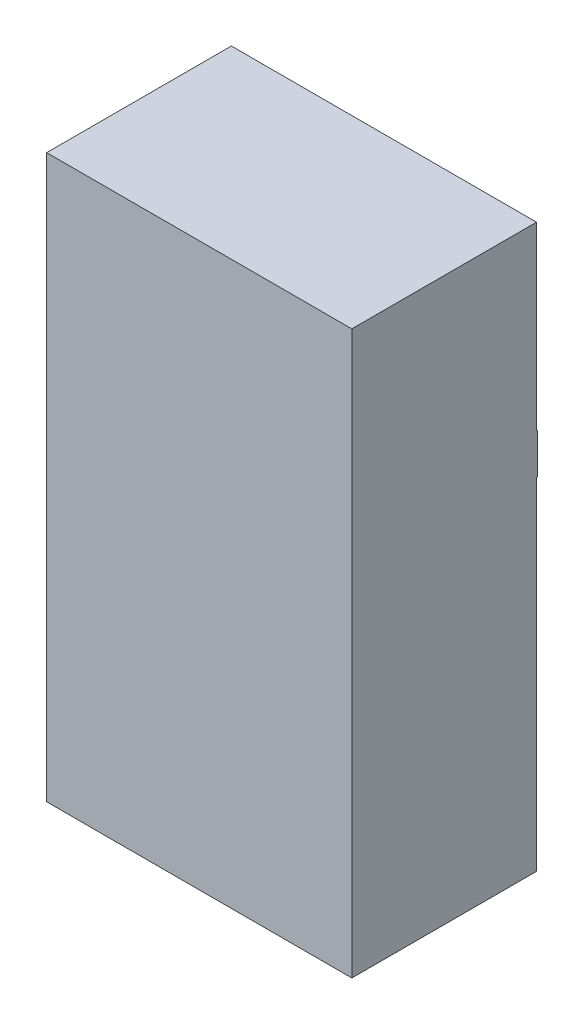
from build123d import *

# Parameters (mm, degrees)
SKETCH2_W           = 38
SKETCH2_H           = 70
BOSS_EXTRUDE1_DEPTH = 23
CUT_EXTRUDE1_DEPTH  = 5
SKETCH5_W           = 38
SKETCH5_H           = 5
BOSS_EXTRUDE2_DEPTH = 0.1


with BuildPart() as part:
    # Sketch2 → Boss-Extrude1 (new body)
    with BuildSketch(Plane.XY):
        with Locations((19, 35)):
            Rectangle(SKETCH2_W, SKETCH2_H)
    extrude(amount=BOSS_EXTRUDE1_DEPTH)

    # Sketch4 → Cut-Extrude1 (cut)
    with BuildSketch(Plane.XZ):
        Polygon((6.979744589, 9.266725674), (7.703302281, 9.266725674), (7.215321512, 5.766725674), (6.899115583, 5.766725674), (7.342925679, 8.95262311), (6.854243788, 8.95262311), align=None)
        with BuildLine():
            Line((9.232448916, 8.234674392), (8.918346352, 8.234674392))
            add(Edge.make_bspline(
                [(8.918346352, 8.234674392), (8.921404998, 8.277985688), (8.927382861, 8.362633924), (8.947560408, 8.485334724), (8.974123344, 8.601053909), (9.011109613, 8.708493662), (9.054820279, 8.809061381), (9.10885762, 8.901106073), (9.169714773, 8.986644508), (9.239375102, 9.063736796), (9.315817706, 9.132483404), (9.398253231, 9.192493683), (9.486261894, 9.243013897), (9.579643232, 9.284924652), (9.678695626, 9.316856804), (9.78285624, 9.340196697), (9.892564469, 9.353448905), (9.967423285, 9.355445875), (10.005786256, 9.356469263)],
                knots=[0, 0, 0, 0, 0.000130192, 0.000254449, 0.000372639, 0.000485937, 0.000594855, 0.00070104, 0.000805528, 0.000909287, 0.001012056, 0.00111345, 0.001214589, 0.001315961, 0.001419947, 0.001526261, 0.001635748, 0.001750837, 0.001750837, 0.001750837, 0.001750837], degree=3))
            add(Edge.make_bspline(
                [(10.005786256, 9.356469263), (10.038299227, 9.355591073), (10.102377473, 9.353860291), (10.196475235, 9.342292938), (10.286155658, 9.320586683), (10.371988963, 9.292425627), (10.453094462, 9.254416035), (10.530959012, 9.209812374), (10.603700489, 9.155207818), (10.672197003, 9.09394677), (10.73413122, 9.02647119), (10.788260387, 8.954438471), (10.835576032, 8.879247805), (10.872088268, 8.798706838), (10.902279833, 8.715206513), (10.922064933, 8.627321618), (10.93534647, 8.535861769), (10.936824556, 8.473338793), (10.937577121, 8.441505321)],
                knots=[0, 0, 0, 0, 9.7547e-05, 0.00019225, 0.000283743, 0.000373981, 0.000462761, 0.000551988, 0.000642715, 0.000735061, 0.000827359, 0.000916963, 0.001005106, 0.00109325, 0.001181728, 0.001271013, 0.001363028, 0.001458473, 0.001458473, 0.001458473, 0.001458473], degree=3))
            add(Edge.make_bspline(
                [(10.937577121, 8.441505321), (10.936006916, 8.396274677), (10.932848966, 8.305308177), (10.905363919, 8.169744325), (10.86230564, 8.034981832), (10.811777684, 7.922268972), (10.75649713, 7.827470766), (10.700933322, 7.744436131), (10.631178589, 7.650602804), (10.547113219, 7.546096009), (10.449689153, 7.430080578), (10.339012457, 7.302166818), (10.21313159, 7.164319354), (10.123927664, 7.069298054), (10.077300679, 7.019630321)],
                knots=[0, 0, 0, 0, 0.000135578, 0.00027267, 0.000413248, 0.000559472, 0.000642088, 0.000742233, 0.000859043, 0.000992739, 0.001144539, 0.00131352, 0.001500142, 0.001704517, 0.001704517, 0.001704517, 0.001704517], degree=3))
            Line((10.077300679, 7.019630321), (9.214219749, 6.080828238))
            Line((9.214219749, 6.080828238), (10.758089941, 6.080828238))
            Line((10.758089941, 6.080828238), (10.718125999, 5.766725674))
            Line((10.718125999, 5.766725674), (8.514500198, 5.766725674))
            Line((8.514500198, 5.766725674), (9.687476961, 7.042066218))
            add(Edge.make_bspline(
                [(9.687476961, 7.042066218), (9.714842051, 7.071961412), (9.768234666, 7.130290565), (9.845960976, 7.215915572), (9.919930462, 7.296957939), (9.988339212, 7.375234732), (10.053620121, 7.448577451), (10.114783756, 7.51807935), (10.171432093, 7.583680395), (10.223520737, 7.645838738), (10.271690341, 7.70377572), (10.315986747, 7.757480212), (10.35532392, 7.80780957), (10.391120435, 7.853475538), (10.421993012, 7.896113347), (10.449474912, 7.934040772), (10.471765334, 7.968820884), (10.508253726, 8.025940748), (10.549939595, 8.110261328), (10.592529907, 8.222262679), (10.61813457, 8.333787714), (10.621718531, 8.407965221), (10.623474557, 8.444309808)],
                knots=[0, 0, 0, 0, 0.000121586, 0.000237228, 0.000346928, 0.000450744, 0.000549086, 0.000641491, 0.000728489, 0.000809103, 0.000884779, 0.000954533, 0.001017933, 0.001076412, 0.001128579, 0.001175851, 0.001216883, 0.001252482, 0.00137916, 0.001498066, 0.001611529, 0.001720528, 0.001720528, 0.001720528, 0.001720528], degree=3))
            add(Edge.make_bspline(
                [(10.623474557, 8.444309808), (10.62294601, 8.464903108), (10.621908346, 8.505332738), (10.613397763, 8.564859753), (10.598609208, 8.621691398), (10.578088122, 8.676189044), (10.5519192, 8.728284552), (10.52042871, 8.77843098), (10.482207177, 8.825385914), (10.438817844, 8.869308678), (10.391430444, 8.90962246), (10.341069106, 8.946044958), (10.286454701, 8.975111043), (10.229648356, 9.000067494), (10.169379577, 9.018803237), (10.106397268, 9.033158579), (10.039852328, 9.040603221), (9.994584091, 9.041769961), (9.971431288, 9.042366699)],
                knots=[0, 0, 0, 0, 6.1762e-05, 0.000121255, 0.000179923, 0.000237611, 0.000295618, 0.000354554, 0.000414887, 0.00047686, 0.000539524, 0.000601385, 0.000662881, 0.000724746, 0.000787276, 0.000851916, 0.000918272, 0.000987739, 0.000987739, 0.000987739, 0.000987739], degree=3))
            add(Edge.make_bspline(
                [(9.971431288, 9.042366699), (9.945688465, 9.041687411), (9.895412769, 9.040360763), (9.821740243, 9.03013164), (9.751388874, 9.014336911), (9.684307436, 8.991135393), (9.621244331, 8.960551916), (9.560912211, 8.924850172), (9.504588874, 8.881649781), (9.452285266, 8.831997043), (9.404324341, 8.776513568), (9.362349322, 8.715208132), (9.325420269, 8.648669803), (9.294768747, 8.576507833), (9.270251612, 8.498724184), (9.251528159, 8.415695698), (9.237837306, 8.327150861), (9.234276547, 8.266040507), (9.232448916, 8.234674392)],
                knots=[0, 0, 0, 0, 7.7203e-05, 0.000150777, 0.00022272, 0.000293231, 0.000363164, 0.000432664, 0.000503199, 0.000575608, 0.00064869, 0.000722787, 0.000798104, 0.000876633, 0.000957566, 0.001042437, 0.001131777, 0.001225988, 0.001225988, 0.001225988, 0.001225988], degree=3))
        make_face()
        with BuildLine():
            add(Edge.make_bspline(
                [(12.783630807, 9.356469263), (12.816185654, 9.355380972), (12.880300218, 9.353237656), (12.974210479, 9.336570693), (13.064239977, 9.309911751), (13.150018933, 9.271945842), (13.231385531, 9.222465577), (13.309701586, 9.163853532), (13.382532563, 9.092538803), (13.451958795, 9.012363358), (13.515172206, 8.921930028), (13.569711731, 8.821517246), (13.617045761, 8.712610538), (13.654531775, 8.594077775), (13.683819939, 8.466975281), (13.70465909, 8.330825047), (13.717362736, 8.185838976), (13.718859968, 8.086063286), (13.719628403, 8.03485468)],
                knots=[0, 0, 0, 0, 9.7617e-05, 0.00019225, 0.000285193, 0.000378735, 0.000472763, 0.000570361, 0.000671517, 0.000777907, 0.000888188, 0.001001779, 0.001120171, 0.001243895, 0.001374169, 0.001511111, 0.001656791, 0.001810394, 0.001810394, 0.001810394, 0.001810394], degree=3))
            add(Edge.make_bspline(
                [(13.719628403, 8.03485468), (13.718998903, 7.975240825), (13.717756184, 7.857554783), (13.706567071, 7.683348226), (13.690515803, 7.513625592), (13.665469317, 7.348817676), (13.634893905, 7.188471261), (13.597057139, 7.032843549), (13.552267732, 6.881857429), (13.500439329, 6.736743998), (13.444109643, 6.59937413), (13.385407508, 6.470794688), (13.32287212, 6.353354074), (13.258848089, 6.245201747), (13.190288513, 6.148607379), (13.120868351, 6.060735608), (13.046597581, 5.985027099), (12.970731186, 5.918516791), (12.89237785, 5.861765077), (12.813086544, 5.812239257), (12.732147201, 5.771138109), (12.650580892, 5.735834602), (12.566691558, 5.71028402), (12.481844129, 5.691448818), (12.39560061, 5.678565232), (12.337530144, 5.677512515), (12.30827023, 5.676982084)],
                knots=[0, 0, 0, 0, 0.00017882, 0.000353016, 0.00052352, 0.000690101, 0.000852906, 0.001013094, 0.001170372, 0.00132516, 0.001475149, 0.001615688, 0.001748985, 0.001874156, 0.001992421, 0.002104109, 0.002209718, 0.002310103, 0.002406446, 0.002499642, 0.002590263, 0.002678552, 0.002765925, 0.002852847, 0.002939211, 0.003026921, 0.003026921, 0.003026921, 0.003026921], degree=3))
            add(Edge.make_bspline(
                [(12.30827023, 5.676982084), (12.265123953, 5.678699245), (12.180546974, 5.68206529), (12.057772794, 5.709598307), (11.942835662, 5.754104827), (11.853910392, 5.805744359), (11.788107205, 5.855965272), (11.740719717, 5.898150508), (11.696693282, 5.945520694), (11.654589271, 5.996825618), (11.614309465, 6.052261773), (11.577316172, 6.112991311), (11.54228373, 6.177986034), (11.510026173, 6.247765434), (11.480201769, 6.322167593), (11.455236445, 6.402162824), (11.434286588, 6.487452699), (11.41694949, 6.577806171), (11.402815006, 6.673214927), (11.393115694, 6.773833912), (11.387619371, 6.879811184), (11.386743856, 6.952316194), (11.38629507, 6.989482084)],
                knots=[0, 0, 0, 0, 0.000129328, 0.000253514, 0.000375382, 0.000497918, 0.000560459, 0.000623517, 0.000687998, 0.000754249, 0.00082255, 0.000893377, 0.000967408, 0.001043946, 0.001123886, 0.001207705, 0.001295109, 0.001387236, 0.001483614, 0.001584354, 0.001690372, 0.00180187, 0.00180187, 0.00180187, 0.00180187], degree=3))
            add(Edge.make_bspline(
                [(11.38629507, 6.989482084), (11.386991465, 7.051428267), (11.388361488, 7.173295554), (11.398486418, 7.353137496), (11.414234791, 7.526974668), (11.437199595, 7.694767297), (11.467805141, 7.856243933), (11.503090902, 8.012274881), (11.54573638, 8.162370576), (11.595592768, 8.305584618), (11.649885385, 8.440719282), (11.707506235, 8.566916383), (11.768035806, 8.683344118), (11.832607907, 8.78934146), (11.899958871, 8.885437973), (11.970906741, 8.971108401), (12.044587213, 9.047534236), (12.12191302, 9.113579447), (12.201739514, 9.170003309), (12.281406836, 9.220635224), (12.363267038, 9.261667965), (12.445297184, 9.29643271), (12.528552586, 9.323414862), (12.612879406, 9.341930879), (12.697931371, 9.354835339), (12.755071031, 9.35592475), (12.783630807, 9.356469263)],
                knots=[0, 0, 0, 0, 0.00018583, 0.000365586, 0.00054021, 0.000709368, 0.00087342, 0.001033123, 0.00118914, 0.001341246, 0.001487846, 0.001625889, 0.001757291, 0.001881262, 0.001997978, 0.002109023, 0.002214632, 0.002316079, 0.002413558, 0.00250772, 0.002598966, 0.0026879, 0.002774817, 0.002861055, 0.002946724, 0.003032332, 0.003032332, 0.003032332, 0.003032332], degree=3))
        make_face()
        with BuildLine():
            add(Edge.make_bspline(
                [(12.759792666, 9.042366699), (12.74081819, 9.041646628), (12.702624487, 9.040197197), (12.64511374, 9.02965823), (12.586742982, 9.013718756), (12.527454824, 8.990094395), (12.467675082, 8.959872323), (12.406645806, 8.923741028), (12.34509711, 8.880789739), (12.28265072, 8.831361782), (12.221482293, 8.77360669), (12.162580375, 8.707503129), (12.106247454, 8.632741514), (12.05316179, 8.548741391), (12.001899641, 8.456140944), (11.953845216, 8.35435414), (11.90832662, 8.244107136), (11.865767101, 8.125730709), (11.826421037, 8.000305531), (11.79307251, 7.867958987), (11.764104224, 7.730014789), (11.741595854, 7.585762036), (11.72198352, 7.436008464), (11.710113484, 7.280131661), (11.702045545, 7.118573992), (11.700953739, 7.008890448), (11.700397634, 6.953023751)],
                knots=[0, 0, 0, 0, 5.6899e-05, 0.000114532, 0.000174918, 0.000238194, 0.000305607, 0.000375709, 0.000450782, 0.000530605, 0.000614426, 0.000702812, 0.000795922, 0.000894919, 0.001000677, 0.001113263, 0.0012324, 0.001358372, 0.00149054, 0.00162658, 0.00176766, 0.001913241, 0.00206447, 0.00222063, 0.002382072, 0.002549664, 0.002549664, 0.002549664, 0.002549664], degree=3))
            add(Edge.make_bspline(
                [(11.700397634, 6.953023751), (11.700862956, 6.913506622), (11.701761699, 6.837181545), (11.710708238, 6.726542575), (11.723077505, 6.623539693), (11.743089863, 6.528789562), (11.767185363, 6.441501192), (11.798076424, 6.36252343), (11.833718152, 6.2908168), (11.87529278, 6.2275779), (11.920913065, 6.172108899), (11.969588185, 6.123949992), (12.020941755, 6.08320862), (12.074446938, 6.048944973), (12.131044818, 6.022703131), (12.190544522, 6.004658956), (12.2524145, 5.992857818), (12.294661068, 5.991679391), (12.31598257, 5.991084648)],
                knots=[0, 0, 0, 0, 0.000118523, 0.00022892, 0.000332842, 0.000429508, 0.000519169, 0.00060419, 0.000683519, 0.000758971, 0.000830698, 0.00089862, 0.00096399, 0.001027013, 0.001088811, 0.001150462, 0.001213172, 0.001277071, 0.001277071, 0.001277071, 0.001277071], degree=3))
            add(Edge.make_bspline(
                [(12.31598257, 5.991084648), (12.338230857, 5.991711498), (12.382778996, 5.992966652), (12.449138692, 6.004687542), (12.51457895, 6.023848642), (12.579370115, 6.0499769), (12.643644124, 6.083346148), (12.707477409, 6.123855375), (12.769819851, 6.173082053), (12.83221369, 6.227978954), (12.892488691, 6.290555515), (12.94984654, 6.359963752), (13.003923752, 6.435910799), (13.054279668, 6.518376533), (13.102084524, 6.606708067), (13.146130383, 6.701599974), (13.18698885, 6.802971581), (13.210952935, 6.873440122), (13.223234172, 6.909554199)],
                knots=[0, 0, 0, 0, 6.6699e-05, 0.000133552, 0.000201449, 0.000270973, 0.000342782, 0.000418442, 0.000497398, 0.000580835, 0.000667607, 0.000757736, 0.000850732, 0.000947051, 0.001047436, 0.001151887, 0.00126073, 0.001375149, 0.001375149, 0.001375149, 0.001375149], degree=3))
            add(Edge.make_bspline(
                [(13.223234172, 6.909554199), (13.237886568, 6.955944171), (13.267308591, 7.049095274), (13.304350581, 7.191337798), (13.33475187, 7.336068996), (13.36136248, 7.48276474), (13.380289976, 7.632147702), (13.395517359, 7.783592315), (13.403877834, 7.937536741), (13.404973443, 8.040921957), (13.405525839, 8.093047789)],
                knots=[0, 0, 0, 0, 0.000145931, 0.00029303, 0.000440719, 0.000589532, 0.000740155, 0.000892312, 0.001046088, 0.001202463, 0.001202463, 0.001202463, 0.001202463], degree=3))
            add(Edge.make_bspline(
                [(13.405525839, 8.093047789), (13.40500881, 8.131390213), (13.404008092, 8.205602498), (13.395718969, 8.313360003), (13.38109357, 8.413606637), (13.360845723, 8.506667956), (13.335159335, 8.592382353), (13.303650267, 8.670637087), (13.266431596, 8.74162693), (13.222911485, 8.804581784), (13.174981259, 8.860077263), (13.12433779, 8.908740771), (13.07123684, 8.950669604), (13.014334314, 8.983713), (12.954906771, 9.010076815), (12.892527088, 9.028880709), (12.827076536, 9.040640362), (12.782512852, 9.041783756), (12.759792666, 9.042366699)],
                knots=[0, 0, 0, 0, 0.000115018, 0.000222619, 0.000323955, 0.00041871, 0.000508094, 0.000592071, 0.000671422, 0.000748046, 0.000821128, 0.000891047, 0.000958504, 0.001023558, 0.001087912, 0.00115312, 0.001218592, 0.001286691, 0.001286691, 0.001286691, 0.001286691], degree=3))
        make_face(mode=Mode.SUBTRACT)
        Polygon((14.302961736, 9.266725674), (14.628983371, 9.266725674), (15.522913659, 6.475559808), (17.133390422, 9.266725674), (17.488859172, 9.266725674), (15.469628403, 5.766725674), (15.424756608, 5.766725674), align=None)
    extrude(amount=-CUT_EXTRUDE1_DEPTH, mode=Mode.SUBTRACT)

    # Sketch5 → Boss-Extrude2 (add)
    with BuildSketch(Plane(origin=(0, 0, 0), x_dir=(-1, 0, 0), z_dir=(0, 0, -1))):
        with Locations((-19, 45)):
            Rectangle(SKETCH5_W, SKETCH5_H)
    extrude(amount=BOSS_EXTRUDE2_DEPTH)


solid = part.part
